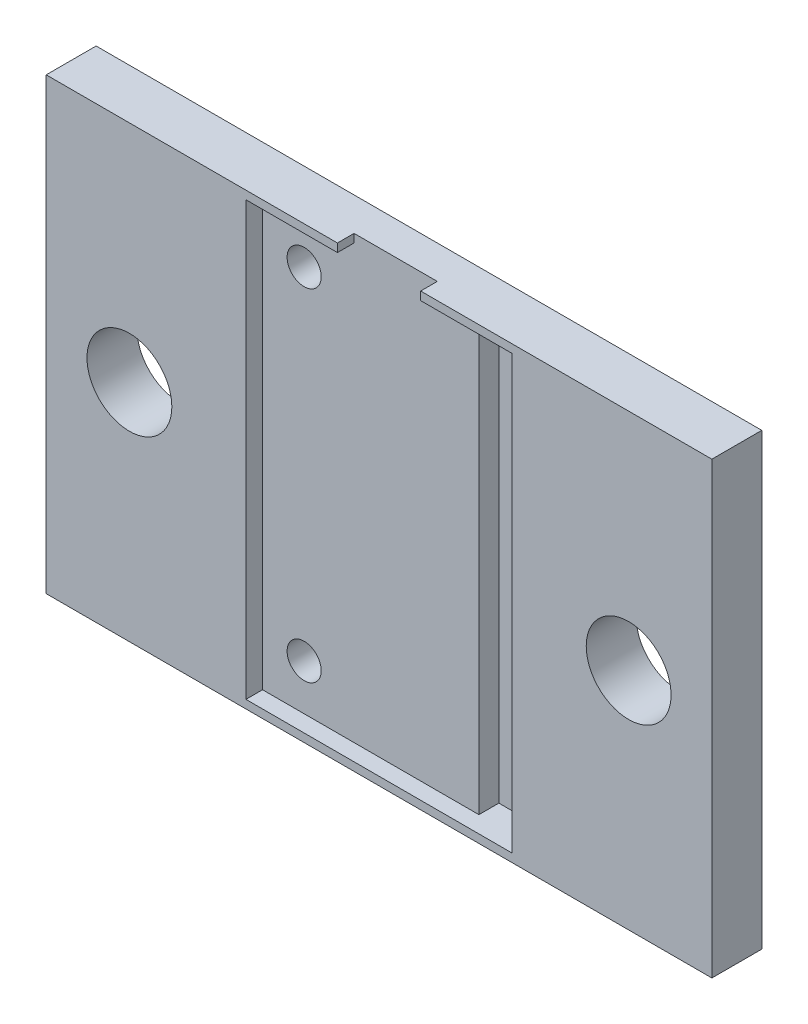
from build123d import *

# Parameters (mm, degrees)
SKETCH3_W           = 40
SKETCH3_H           = 27
SKETCH3_R           = 2.55
BOSS_EXTRUDE1_DEPTH = 3
CUT_EXTRUDE1_DEPTH  = 1
SKETCH5_W           = 3
SKETCH5_H           = 26
CUT_EXTRUDE2_DEPTH  = 1.2
SKETCH6_R           = 1.025
CUT_EXTRUDE3_DEPTH  = 3


with BuildPart() as part:
    # Sketch3 → Boss-Extrude1 (new body)
    with BuildSketch(Plane.XY):
        Rectangle(SKETCH3_W, SKETCH3_H)
        with Locations((-15, 0)):
            Circle(SKETCH3_R, mode=Mode.SUBTRACT)
        with Locations((15, 0)):
            Circle(SKETCH3_R, mode=Mode.SUBTRACT)
    extrude(amount=BOSS_EXTRUDE1_DEPTH)

    # Sketch4 → Cut-Extrude1 (cut)
    with BuildSketch(Plane.XY.offset(3)):
        Polygon((-8, 13), (-8, -13), (8, -13), (8, 13), (2.5, 13), (2.5, 13.5), (-2.5, 13.5), (-2.5, 13), align=None)
    extrude(amount=-CUT_EXTRUDE1_DEPTH, mode=Mode.SUBTRACT)

    # Sketch5 → Cut-Extrude2 (cut)
    with BuildSketch(Plane.XY.offset(2)):
        with Locations((6.5, 0)):
            Rectangle(SKETCH5_W, SKETCH5_H)
    extrude(amount=-CUT_EXTRUDE2_DEPTH, mode=Mode.SUBTRACT)

    # Sketch6 → Cut-Extrude3 (cut)
    with BuildSketch(Plane.XY.offset(2)):
        with Locations((-5.5, 10.25)):
            Circle(SKETCH6_R)
        with Locations((-5.5, -10.25)):
            Circle(SKETCH6_R)
    extrude(amount=-CUT_EXTRUDE3_DEPTH, mode=Mode.SUBTRACT)


solid = part.part
